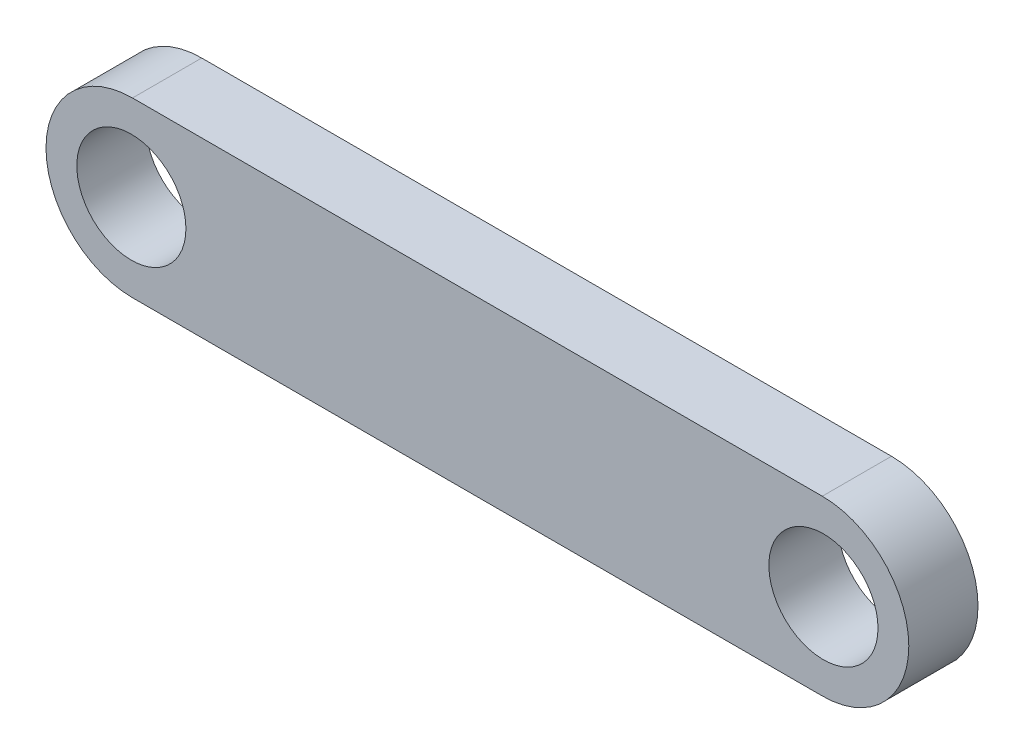
from build123d import *

# Parameters (mm, degrees)
SKETCH1_R           = 2.395
BOSS_EXTRUDE1_DEPTH = 3
SKETCH2_R           = 2.365
BOSS_EXTRUDE2_DEPTH = 3


with BuildPart() as part:
    # Sketch1 → Boss-Extrude1 (new body)
    with BuildSketch(Plane.XY):
        with BuildLine():
            Line((0, 3), (30, 3))
            ThreePointArc((30, 3), (33, 0), (30, -3))
            Line((30, -3), (0, -3))
            ThreePointArc((0, -3), (-3, 0), (0, 3))
        make_face()
        Circle(SKETCH1_R, mode=Mode.SUBTRACT)
        with Locations((30, 0)):
            Circle(SKETCH1_R, mode=Mode.SUBTRACT)
    extrude(amount=BOSS_EXTRUDE1_DEPTH)

    # Sketch2 → Boss-Extrude2 (add)
    with BuildSketch(Plane.XY.offset(3)):
        with BuildLine():
            Line((0.05, 3.75), (29.95, 3.75))
            ThreePointArc((29.95, 3.75), (33.7, 0), (29.95, -3.75))
            Line((29.95, -3.75), (0.05, -3.75))
            ThreePointArc((0.05, -3.75), (-3.7, 0), (0.05, 3.75))
        make_face()
        Circle(SKETCH2_R, mode=Mode.SUBTRACT)
        with Locations((30, 0)):
            Circle(SKETCH2_R, mode=Mode.SUBTRACT)
    extrude(amount=-BOSS_EXTRUDE2_DEPTH)


solid = part.part
